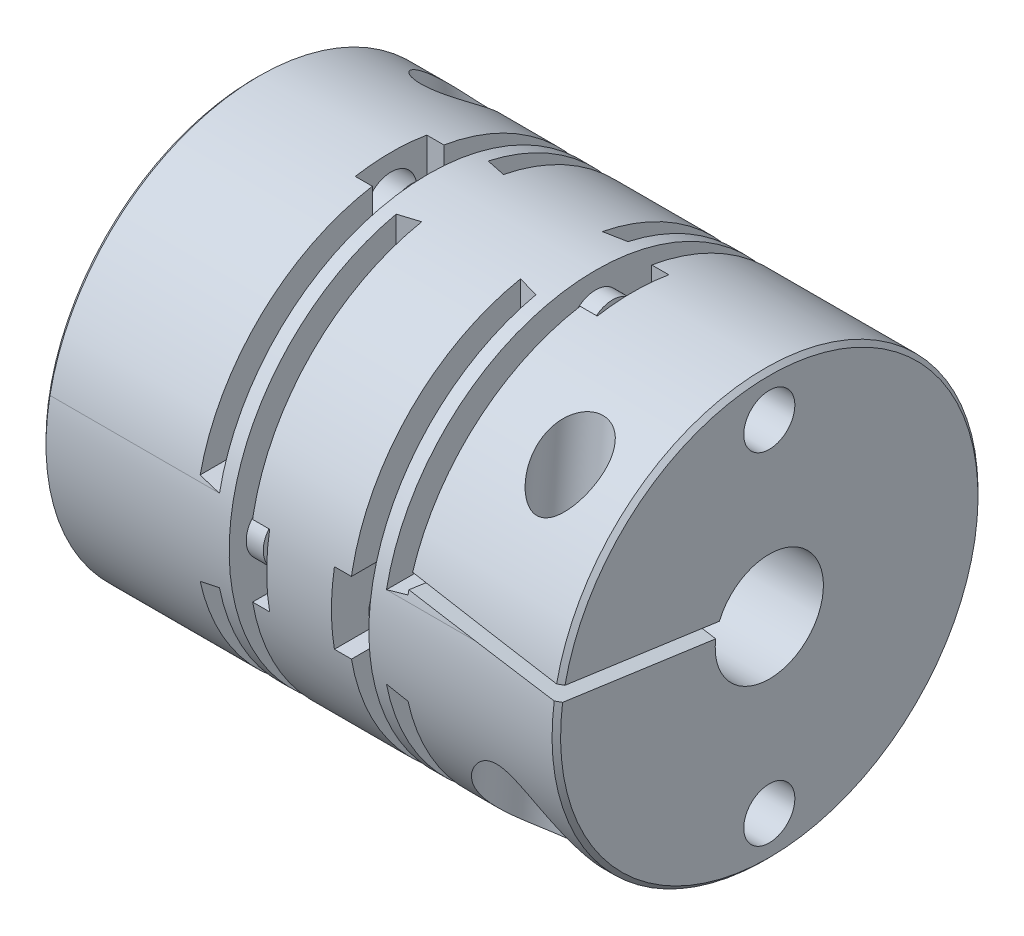
from build123d import *

# Parameters (mm, degrees)
CUT_EXTRUDE1_DEPTH      = 12.5
CUT_EXTRUDE2_DEPTH      = 12.5
CUT_EXTRUDE3_DEPTH      = 12.5
CUT_EXTRUDE3_DEPTH_BACK = 12.5
CUT_EXTRUDE4_DEPTH      = 12.5
CUT_EXTRUDE4_DEPTH_BACK = 12.5
CUT_EXTRUDE5_DEPTH      = 12.5
CUT_EXTRUDE5_DEPTH_BACK = 12.5
CUT_EXTRUDE6_DEPTH      = 12.5
CUT_EXTRUDE6_DEPTH_BACK = 12.5
CUT_EXTRUDE7_DEPTH      = 1
CUT_EXTRUDE8_DEPTH      = 1
CUT_EXTRUDE9_START      = 1
CUT_EXTRUDE9_DEPTH      = 1
CUT_EXTRUDE10_START     = 1
CUT_EXTRUDE10_DEPTH     = 1
CUT_EXTRUDE11_DEPTH     = 1
CUT_EXTRUDE12_DEPTH     = 1
CUT_EXTRUDE13_START     = 1
CUT_EXTRUDE13_DEPTH     = 1
CUT_EXTRUDE14_START     = 1
CUT_EXTRUDE14_DEPTH     = 1
SKETCH18_R              = 1.5
BOSS_EXTRUDE1_DEPTH     = 1
SKETCH19_R              = 1.5
BOSS_EXTRUDE2_DEPTH     = 1
SKETCH20_R              = 1.5
BOSS_EXTRUDE3_DEPTH     = 1
SKETCH21_R              = 1.5
BOSS_EXTRUDE4_DEPTH     = 1
BOSS_EXTRUDE5_START     = -1
SKETCH22_R              = 1.5
BOSS_EXTRUDE5_DEPTH     = 1
BOSS_EXTRUDE6_START     = -1
SKETCH23_R              = 1.5
BOSS_EXTRUDE6_DEPTH     = 1
BOSS_EXTRUDE7_START     = 1
SKETCH24_R              = 1.5
BOSS_EXTRUDE7_DEPTH     = 1
BOSS_EXTRUDE8_START     = 1
SKETCH25_R              = 1.5
BOSS_EXTRUDE8_DEPTH     = 1
CUT_EXTRUDE15_START     = 9
SKETCH26_R              = 1.5
CUT_EXTRUDE15_DEPTH     = 9
CUT_EXTRUDE16_START     = 9
SKETCH27_R              = 1.5
CUT_EXTRUDE16_DEPTH     = 9
SKETCH28_R              = 1.5
CUT_EXTRUDE17_DEPTH     = 9
SKETCH29_R              = 1.5
CUT_EXTRUDE18_DEPTH     = 9


with BuildPart() as part:
    # Sketch1 → Revolve1 (revolve)
    with BuildSketch(Plane.XY):
        Polygon((0, 3.175), (9, 3.175), (9, 5.2), (21.2, 5.2), (21.2, 3.175), (30.2, 3.175), (30.2, 12.25), (29.95, 12.5), (0.25, 12.5), (0, 12.25), align=None)
    revolve(axis=Axis((30.2, 0, 0), (-1, 0, 0)))

    # Sketch2 → Cut-Extrude1 (cut)
    with BuildSketch(Plane(origin=(0, 0, 0), x_dir=(1, 0, 0), z_dir=(0, -0.13917310096007, 0.9902680687415697))):
        Polygon((-1.351352679, 1.435577403), (-1.240014198, 0.643362948), (10.2, 2.251152093), (10.2, 3.059014151), align=None)
    extrude(amount=-CUT_EXTRUDE1_DEPTH, mode=Mode.SUBTRACT)

    # Sketch3 → Cut-Extrude2 (cut)
    with BuildSketch(Plane(origin=(0, 0, 0), x_dir=(1, 0, 0), z_dir=(0, 0.13917310096007, 0.9902680687415697))):
        Polygon((20, 1.379094107), (30.2, 0), (30.307188948, 0.79278656), (20, 2.186373182), align=None)
    extrude(amount=CUT_EXTRUDE2_DEPTH, mode=Mode.SUBTRACT)

    # Sketch4 → Cut-Revolve1 (revolve, cut)
    with BuildSketch(Plane(origin=(4, 0, 0), x_dir=(0, 0, -1), z_dir=(1, 0, 0))):
        Polygon((7.378208149, 13.19325754), (9.171358606, 13.350137876), (9.825026677, 5.878677641), (9.526168267, 5.852530918), (9.28027323, 5.559484624), (9.668900687, 1.117452465), (9.961946981, 0.871557427), (10.223414209, -2.117026667), (11.867135461, -1.973219691), (12.695115017, -11.437069323), (9.557101718, -11.711609913), align=None)
    revolve(axis=Axis((4, -11.711609913, -9.557101718), (0, 0.9961946980917455, 0.08715574274765878)), mode=Mode.SUBTRACT)

    # Sketch5 → Cut-Revolve2 (revolve, cut)
    with BuildSketch(Plane(origin=(26.2, 0, 0), x_dir=(0, 0, -1), z_dir=(1, 0, 0))):
        Polygon((-7.378208149, 13.19325754), (-5.585057693, 13.036377203), (-6.238725763, 5.564916967), (-6.537584173, 5.59106369), (-6.830630467, 5.345168652), (-7.14953333, 1.700092252), (-6.903638292, 1.407045958), (-7.234830115, -2.378493895), (-5.591108863, -2.522300871), (-6.419088419, -11.986150502), (-9.557101718, -11.711609913), align=None)
    revolve(axis=Axis((26.2, -11.711609913, 9.557101718), (0, 0.9961946980917455, -0.08715574274765878)), mode=Mode.SUBTRACT)

    # Sketch6 → Cut-Extrude3 (cut, two sides: drawn at the far end of the back side and taken through both)
    with BuildSketch(Plane.XY.offset(-CUT_EXTRUDE3_DEPTH_BACK)):
        Polygon((9, 13), (9, 2.7), (10.2, 2.4), (10.2, 12.5), (20, 12.5), (20, 2.4), (21.2, 2.7), (21.2, 13), align=None)
    extrude(amount=CUT_EXTRUDE3_DEPTH + CUT_EXTRUDE3_DEPTH_BACK, mode=Mode.SUBTRACT)

    # Sketch7 → Cut-Extrude4 (cut, two sides: drawn at the far end of the back side and taken through both)
    with BuildSketch(Plane.XY.offset(-CUT_EXTRUDE4_DEPTH_BACK)):
        Polygon((9, -13), (21.2, -13), (21.2, -2.7), (20, -2.4), (20, -12.5), (10.2, -12.5), (10.2, -2.4), (9, -2.7), align=None)
    extrude(amount=CUT_EXTRUDE4_DEPTH + CUT_EXTRUDE4_DEPTH_BACK, mode=Mode.SUBTRACT)

    # Sketch8 → Cut-Extrude5 (cut, two sides: drawn at the far end of the back side and taken through both)
    with BuildSketch(Plane(origin=(0, 0, 0), x_dir=(-1, 0, 0), z_dir=(0, 1, 0)).offset(-CUT_EXTRUDE5_DEPTH_BACK)):
        Polygon((-11, -13), (-11, -2.7), (-12.2, -2.4), (-12.2, -12.5), (-18, -12.5), (-18, -2.4), (-19.2, -2.7), (-19.2, -13), align=None)
    extrude(amount=CUT_EXTRUDE5_DEPTH + CUT_EXTRUDE5_DEPTH_BACK, mode=Mode.SUBTRACT)

    # Sketch9 → Cut-Extrude6 (cut, two sides: drawn at the far end of the back side and taken through both)
    with BuildSketch(Plane(origin=(0, 0, 0), x_dir=(-1, 0, 0), z_dir=(0, 1, 0)).offset(-CUT_EXTRUDE6_DEPTH_BACK)):
        Polygon((-11, 13), (-19.2, 13), (-19.2, 2.7), (-18, 2.4), (-18, 12.5), (-12.2, 12.5), (-12.2, 2.4), (-11, 2.7), align=None)
    extrude(amount=CUT_EXTRUDE6_DEPTH + CUT_EXTRUDE6_DEPTH_BACK, mode=Mode.SUBTRACT)

    # Sketch10 → Cut-Extrude7 (cut)
    with BuildSketch(Plane(origin=(18, 0, 0), x_dir=(0, 0, -1), z_dir=(1, 0, 0))):
        with BuildLine():
            Line((-12.5, -2.1), (-10, -2.1))
            ThreePointArc((-10, -2.1), (-7.9, 0), (-10, 2.1))
            Line((-10, 2.1), (-12.5, 2.1))
            Line((-12.5, 2.1), (-12.5, -2.1))
        make_face()
    extrude(amount=-CUT_EXTRUDE7_DEPTH, mode=Mode.SUBTRACT)

    # Sketch11 → Cut-Extrude8 (cut)
    with BuildSketch(Plane(origin=(18, 0, 0), x_dir=(0, 0, -1), z_dir=(1, 0, 0))):
        with BuildLine():
            Line((10, -2.1), (12.5, -2.1))
            Line((12.5, -2.1), (12.5, 2.1))
            Line((12.5, 2.1), (10, 2.1))
            ThreePointArc((10, 2.1), (7.9, 0), (10, -2.1))
        make_face()
    extrude(amount=-CUT_EXTRUDE8_DEPTH, mode=Mode.SUBTRACT)

    # Sketch12 → Cut-Extrude9 (cut)
    with BuildSketch(Plane(origin=(12.2, 0, 0), x_dir=(0, 0, -1), z_dir=(1, 0, 0)).offset(CUT_EXTRUDE9_START)):
        with BuildLine():
            Line((-12.5, -2.1), (-10, -2.1))
            ThreePointArc((-10, -2.1), (-7.9, 0), (-10, 2.1))
            Line((-10, 2.1), (-12.5, 2.1))
            Line((-12.5, 2.1), (-12.5, -2.1))
        make_face()
    extrude(amount=-CUT_EXTRUDE9_DEPTH, mode=Mode.SUBTRACT)

    # Sketch13 → Cut-Extrude10 (cut)
    with BuildSketch(Plane(origin=(12.2, 0, 0), x_dir=(0, 0, -1), z_dir=(1, 0, 0)).offset(CUT_EXTRUDE10_START)):
        with BuildLine():
            Line((10, -2.1), (12.5, -2.1))
            Line((12.5, -2.1), (12.5, 2.1))
            Line((12.5, 2.1), (10, 2.1))
            ThreePointArc((10, 2.1), (7.9, 0), (10, -2.1))
        make_face()
    extrude(amount=-CUT_EXTRUDE10_DEPTH, mode=Mode.SUBTRACT)

    # Sketch14 → Cut-Extrude11 (cut)
    with BuildSketch(Plane(origin=(9, 0, 0), x_dir=(0, 0, -1), z_dir=(1, 0, 0))):
        with BuildLine():
            Line((2.1, 10), (2.1, 12.5))
            Line((2.1, 12.5), (-2.1, 12.5))
            Line((-2.1, 12.5), (-2.1, 10))
            ThreePointArc((-2.1, 10), (0, 7.9), (2.1, 10))
        make_face()
    extrude(amount=-CUT_EXTRUDE11_DEPTH, mode=Mode.SUBTRACT)

    # Sketch15 → Cut-Extrude12 (cut)
    with BuildSketch(Plane(origin=(9, 0, 0), x_dir=(0, 0, -1), z_dir=(1, 0, 0))):
        with BuildLine():
            Line((-2.1, -10), (-2.1, -12.5))
            Line((-2.1, -12.5), (2.1, -12.5))
            Line((2.1, -12.5), (2.1, -10))
            ThreePointArc((2.1, -10), (0, -7.9), (-2.1, -10))
        make_face()
    extrude(amount=-CUT_EXTRUDE12_DEPTH, mode=Mode.SUBTRACT)

    # Sketch16 → Cut-Extrude13 (cut)
    with BuildSketch(Plane(origin=(21.2, 0, 0), x_dir=(0, 0, -1), z_dir=(1, 0, 0)).offset(CUT_EXTRUDE13_START)):
        with BuildLine():
            Line((2.1, 10), (2.1, 12.5))
            Line((2.1, 12.5), (-2.1, 12.5))
            Line((-2.1, 12.5), (-2.1, 10))
            ThreePointArc((-2.1, 10), (0, 7.9), (2.1, 10))
        make_face()
    extrude(amount=-CUT_EXTRUDE13_DEPTH, mode=Mode.SUBTRACT)

    # Sketch17 → Cut-Extrude14 (cut)
    with BuildSketch(Plane(origin=(21.2, 0, 0), x_dir=(0, 0, -1), z_dir=(1, 0, 0)).offset(CUT_EXTRUDE14_START)):
        with BuildLine():
            Line((-2.1, -10), (-2.1, -12.5))
            Line((-2.1, -12.5), (2.1, -12.5))
            Line((2.1, -12.5), (2.1, -10))
            ThreePointArc((2.1, -10), (0, -7.9), (-2.1, -10))
        make_face()
    extrude(amount=-CUT_EXTRUDE14_DEPTH, mode=Mode.SUBTRACT)

    # Sketch18 → Boss-Extrude1 (add)
    with BuildSketch(Plane(origin=(11, 0, 0), x_dir=(0, 0, -1), z_dir=(1, 0, 0))):
        with Locations((-10, 0)):
            Circle(SKETCH18_R)
    extrude(amount=BOSS_EXTRUDE1_DEPTH)

    # Sketch19 → Boss-Extrude2 (add)
    with BuildSketch(Plane(origin=(11, 0, 0), x_dir=(0, 0, -1), z_dir=(1, 0, 0))):
        with Locations((10, 0)):
            Circle(SKETCH19_R)
    extrude(amount=BOSS_EXTRUDE2_DEPTH)

    # Sketch20 → Boss-Extrude3 (add)
    with BuildSketch(Plane(origin=(10.2, 0, 0), x_dir=(0, 0, -1), z_dir=(1, 0, 0))):
        with Locations((0, 10)):
            Circle(SKETCH20_R)
    extrude(amount=-BOSS_EXTRUDE3_DEPTH)

    # Sketch21 → Boss-Extrude4 (add)
    with BuildSketch(Plane(origin=(10.2, 0, 0), x_dir=(0, 0, -1), z_dir=(1, 0, 0))):
        with Locations((0, -10)):
            Circle(SKETCH21_R)
    extrude(amount=-BOSS_EXTRUDE4_DEPTH)

    # Sketch22 → Boss-Extrude5 (add)
    with BuildSketch(Plane(origin=(19.2, 0, 0), x_dir=(0, 0, -1), z_dir=(1, 0, 0)).offset(BOSS_EXTRUDE5_START)):
        with Locations((-10, 0)):
            Circle(SKETCH22_R)
    extrude(amount=BOSS_EXTRUDE5_DEPTH)

    # Sketch23 → Boss-Extrude6 (add)
    with BuildSketch(Plane(origin=(19.2, 0, 0), x_dir=(0, 0, -1), z_dir=(1, 0, 0)).offset(BOSS_EXTRUDE6_START)):
        with Locations((10, 0)):
            Circle(SKETCH23_R)
    extrude(amount=BOSS_EXTRUDE6_DEPTH)

    # Sketch24 → Boss-Extrude7 (add)
    with BuildSketch(Plane(origin=(20, 0, 0), x_dir=(0, 0, -1), z_dir=(1, 0, 0)).offset(BOSS_EXTRUDE7_START)):
        with Locations((0, 10)):
            Circle(SKETCH24_R)
    extrude(amount=-BOSS_EXTRUDE7_DEPTH)

    # Sketch25 → Boss-Extrude8 (add)
    with BuildSketch(Plane(origin=(20, 0, 0), x_dir=(0, 0, -1), z_dir=(1, 0, 0)).offset(BOSS_EXTRUDE8_START)):
        with Locations((0, -10)):
            Circle(SKETCH25_R)
    extrude(amount=-BOSS_EXTRUDE8_DEPTH)

    # Sketch26 → Cut-Extrude15 (cut)
    with BuildSketch(Plane(origin=(0, 0, 0), x_dir=(0, 0, -1), z_dir=(1, 0, 0)).offset(CUT_EXTRUDE15_START)):
        with Locations((0, 10)):
            Circle(SKETCH26_R)
    extrude(amount=-CUT_EXTRUDE15_DEPTH, mode=Mode.SUBTRACT)

    # Sketch27 → Cut-Extrude16 (cut)
    with BuildSketch(Plane(origin=(0, 0, 0), x_dir=(0, 0, -1), z_dir=(1, 0, 0)).offset(CUT_EXTRUDE16_START)):
        with Locations((0, -10)):
            Circle(SKETCH27_R)
    extrude(amount=-CUT_EXTRUDE16_DEPTH, mode=Mode.SUBTRACT)

    # Sketch28 → Cut-Extrude17 (cut)
    with BuildSketch(Plane(origin=(30.2, 0, 0), x_dir=(0, 0, -1), z_dir=(1, 0, 0))):
        with Locations((0, 10)):
            Circle(SKETCH28_R)
    extrude(amount=-CUT_EXTRUDE17_DEPTH, mode=Mode.SUBTRACT)

    # Sketch29 → Cut-Extrude18 (cut)
    with BuildSketch(Plane(origin=(30.2, 0, 0), x_dir=(0, 0, -1), z_dir=(1, 0, 0))):
        with Locations((0, -10)):
            Circle(SKETCH29_R)
    extrude(amount=-CUT_EXTRUDE18_DEPTH, mode=Mode.SUBTRACT)


solid = part.part
